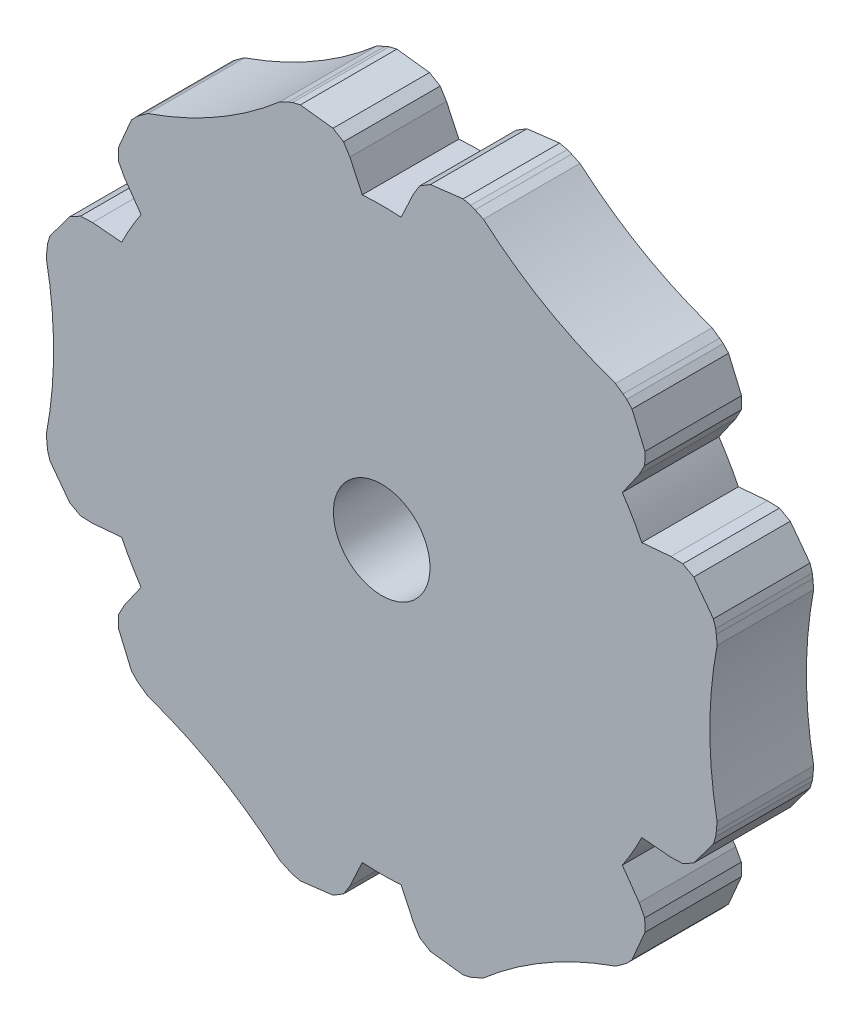
from build123d import *

# Parameters (mm, degrees)
SKETCH1_R           = 3
BOSS_EXTRUDE2_DEPTH = 6
CUT_EXTRUDE1_DEPTH  = 7
CUT_EXTRUDE2_DEPTH  = 7


with BuildPart() as part:
    # Sketch1 → Boss-Extrude2 (new body)
    with BuildSketch(Plane.XY):
        with BuildLine():
            Line((-129.483201213, -12.731798863), (-129.756040866, -10.003402327))
            ThreePointArc((-129.756040866, -10.003402327), (-131.945122685, -10.112584142), (-134.134204503, -10.003402327))
            Line((-134.134204503, -10.003402327), (-134.407044157, -12.731798863))
            ThreePointArc((-134.407044157, -12.731798863), (-142.137187462, -5.76575817), (-152.035027318, -2.554278039))
            Line((-152.035027318, -2.554278039), (-149.808586433, -0.9537937))
            ThreePointArc((-149.808586433, -0.9537937), (-150.997681568, 0.887415858), (-151.997668251, 2.837807232))
            Line((-151.997668251, 2.837807232), (-154.49694879, 1.709895035))
            ThreePointArc((-154.49694879, 1.709895035), (-152.329252239, 11.887415858), (-154.49694879, 22.064936682))
            Line((-154.49694879, 22.064936682), (-151.997668251, 20.937024485))
            ThreePointArc((-151.997668251, 20.937024485), (-150.997681568, 22.887415858), (-149.808586433, 24.728625416))
            Line((-149.808586433, 24.728625416), (-152.035027318, 26.329109756))
            ThreePointArc((-152.035027318, 26.329109756), (-142.137187462, 29.540589886), (-134.407044157, 36.506630579))
            Line((-134.407044157, 36.506630579), (-134.134204503, 33.778234043))
            ThreePointArc((-134.134204503, 33.778234043), (-131.945122685, 33.887415858), (-129.756040866, 33.778234043))
            Line((-129.756040866, 33.778234043), (-129.483201213, 36.506630579))
            ThreePointArc((-129.483201213, 36.506630579), (-121.753057907, 29.540589886), (-111.855218051, 26.329109756))
            Line((-111.855218051, 26.329109756), (-114.081658936, 24.728625416))
            ThreePointArc((-114.081658936, 24.728625416), (-112.892563801, 22.887415858), (-111.892577118, 20.937024485))
            Line((-111.892577118, 20.937024485), (-109.393296579, 22.064936682))
            ThreePointArc((-109.393296579, 22.064936682), (-111.56099313, 11.887415858), (-109.393296579, 1.709895035))
            Line((-109.393296579, 1.709895035), (-111.892577118, 2.837807232))
            ThreePointArc((-111.892577118, 2.837807232), (-112.892563801, 0.887415858), (-114.081658936, -0.9537937))
            Line((-114.081658936, -0.9537937), (-111.855218051, -2.554278039))
            ThreePointArc((-111.855218051, -2.554278039), (-121.753057907, -5.76575817), (-129.483201213, -12.731798863))
        make_face()
        with Locations((-131.945122685, 11.887415858)):
            Circle(SKETCH1_R, mode=Mode.SUBTRACT)
    extrude(amount=BOSS_EXTRUDE2_DEPTH)

    # Sketch2 → Cut-Extrude1 (cut, through all)
    with BuildSketch(Plane(origin=(0, 0, 0), x_dir=(-1, 0, 0), z_dir=(0, 0, -1))):
        with BuildLine():
            ThreePointArc((130.738332945, 29.846952186), (131.945122685, 29.887451596), (133.151912424, 29.846952186))
            Line((133.151912424, 29.846952186), (134.365507242, 32.447465558))
            Line((134.365507242, 32.447465558), (137.658457935, 32.842028481))
            ThreePointArc((137.658457935, 32.842028481), (135.942681801, 34.594415702), (134.407044157, 36.506630579))
            Line((134.407044157, 36.506630579), (134.134204503, 33.778234043))
            ThreePointArc((134.134204503, 33.778234043), (131.945122685, 33.887415858), (129.756040866, 33.778234043))
            Line((129.756040866, 33.778234043), (129.483201213, 36.506630579))
            ThreePointArc((129.483201213, 36.506630579), (127.947563568, 34.594415702), (126.231787434, 32.842028481))
            Line((126.231787434, 32.842028481), (129.524738127, 32.447465558))
            Line((129.524738127, 32.447465558), (130.738332945, 29.846952186))
        make_face()
        with BuildLine():
            Line((148.540455749, 24.263555222), (146.895142515, 21.912294593))
            ThreePointArc((146.895142515, 21.912294593), (147.533610903, 20.887433727), (148.101932254, 19.82207345))
            Line((148.101932254, 19.82207345), (150.960840307, 20.071326194))
            Line((150.960840307, 20.071326194), (152.949017168, 17.416828703))
            ThreePointArc((152.949017168, 17.416828703), (153.608740951, 19.778928032), (154.49694879, 22.064936682))
            Line((154.49694879, 22.064936682), (151.997668251, 20.937024485))
            ThreePointArc((151.997668251, 20.937024485), (150.997681568, 22.887415858), (149.808586433, 24.728625416))
            Line((149.808586433, 24.728625416), (152.035027318, 26.329109756))
            ThreePointArc((152.035027318, 26.329109756), (149.611181835, 26.702903528), (147.235681918, 27.312615637))
            Line((147.235681918, 27.312615637), (148.540455749, 24.263555222))
        make_face()
        with BuildLine():
            ThreePointArc((115.788313115, 19.82207345), (116.356634466, 20.887433727), (116.995102855, 21.912294593))
            Line((116.995102855, 21.912294593), (115.34978962, 24.263555222))
            Line((115.34978962, 24.263555222), (116.654563452, 27.312615637))
            ThreePointArc((116.654563452, 27.312615637), (114.279063535, 26.702903528), (111.855218051, 26.329109756))
            Line((111.855218051, 26.329109756), (114.081658936, 24.728625416))
            ThreePointArc((114.081658936, 24.728625416), (112.892563801, 22.887415858), (111.892577118, 20.937024485))
            Line((111.892577118, 20.937024485), (109.393296579, 22.064936682))
            ThreePointArc((109.393296579, 22.064936682), (110.281504418, 19.778928032), (110.941228201, 17.416828703))
            Line((110.941228201, 17.416828703), (112.929405062, 20.071326194))
            Line((112.929405062, 20.071326194), (115.788313115, 19.82207345))
        make_face()
        with BuildLine():
            Line((150.960840307, 3.703505522), (148.101932254, 3.952758266))
            ThreePointArc((148.101932254, 3.952758266), (147.533610903, 2.887397989), (146.895142515, 1.862537123))
            Line((146.895142515, 1.862537123), (148.540455749, -0.488723506))
            Line((148.540455749, -0.488723506), (147.235681918, -3.537783921))
            ThreePointArc((147.235681918, -3.537783921), (149.611181835, -2.928071812), (152.035027318, -2.554278039))
            Line((152.035027318, -2.554278039), (149.808586433, -0.9537937))
            ThreePointArc((149.808586433, -0.9537937), (150.997681568, 0.887415858), (151.997668251, 2.837807232))
            Line((151.997668251, 2.837807232), (154.49694879, 1.709895035))
            ThreePointArc((154.49694879, 1.709895035), (153.608740951, 3.995903684), (152.949017168, 6.358003014))
            Line((152.949017168, 6.358003014), (150.960840307, 3.703505522))
        make_face()
        with BuildLine():
            ThreePointArc((116.995102855, 1.862537123), (116.356634466, 2.887397989), (115.788313115, 3.952758266))
            Line((115.788313115, 3.952758266), (112.929405062, 3.703505522))
            Line((112.929405062, 3.703505522), (110.941228201, 6.358003014))
            ThreePointArc((110.941228201, 6.358003014), (110.281504418, 3.995903684), (109.393296579, 1.709895035))
            Line((109.393296579, 1.709895035), (111.892577118, 2.837807232))
            ThreePointArc((111.892577118, 2.837807232), (112.892563801, 0.887415858), (114.081658936, -0.9537937))
            Line((114.081658936, -0.9537937), (111.855218051, -2.554278039))
            ThreePointArc((111.855218051, -2.554278039), (114.279063535, -2.928071812), (116.654563452, -3.537783921))
            Line((116.654563452, -3.537783921), (115.34978962, -0.488723506))
            Line((115.34978962, -0.488723506), (116.995102855, 1.862537123))
        make_face()
        with BuildLine():
            Line((134.365507242, -8.672633842), (133.151912424, -6.072120469))
            ThreePointArc((133.151912424, -6.072120469), (131.945122685, -6.11261988), (130.738332945, -6.072120469))
            Line((130.738332945, -6.072120469), (129.524738127, -8.672633842))
            Line((129.524738127, -8.672633842), (126.231787434, -9.067196765))
            ThreePointArc((126.231787434, -9.067196765), (127.947563568, -10.819583986), (129.483201213, -12.731798863))
            Line((129.483201213, -12.731798863), (129.756040866, -10.003402327))
            ThreePointArc((129.756040866, -10.003402327), (131.945122685, -10.112584142), (134.134204503, -10.003402327))
            Line((134.134204503, -10.003402327), (134.407044157, -12.731798863))
            ThreePointArc((134.407044157, -12.731798863), (135.942681801, -10.819583986), (137.658457935, -9.067196765))
            Line((137.658457935, -9.067196765), (134.365507242, -8.672633842))
        make_face()
    extrude(amount=-CUT_EXTRUDE1_DEPTH, mode=Mode.SUBTRACT)

    # Sketch5 → Cut-Extrude2 (cut, through all)
    with BuildSketch(Plane(origin=(0, 0, 0), x_dir=(-1, 0, 0), z_dir=(0, 0, -1))):
        Polygon((130.20552592, 31.11947551), (129.574953313, 32.121497093), (129.310917186, 32.281735325), (128.697286189, 32.654135676), (127.366259017, 32.873895382), (126.416214667, 32.654135676), (126.147436582, 32.54260411), (125.218815368, 32.111317334), (126.147436582, 39.612839074), (129.890239616, 35.341275211), align=None)
        Polygon((137.742808787, 39.612839074), (134.000005753, 35.341275211), (133.68471945, 31.11947551), (134.315292057, 32.121497093), (134.579328183, 32.281735325), (135.19295918, 32.654135676), (136.523986352, 32.873895382), (137.474030702, 32.654135676), (137.742808787, 32.54260411), (138.671430002, 32.111317334), align=None)
        Polygon((151.553547848, 19.458066854), (152.409378922, 18.415243363), (152.694083609, 17.482600968), (152.731883481, 17.194066536), (152.822688785, 16.174213586), (158.854886572, 20.729184019), (153.284202235, 21.834764595), (149.470373293, 19.996910693), (150.653435743, 19.951829588), (150.924224185, 19.803286711), align=None)
        Polygon((148.290018687, 24.365864472), (148.305711352, 25.083484679), (147.830515254, 26.346067876), (147.165175591, 27.058950565), (146.934197379, 27.235953431), (146.096381468, 27.824519606), (153.05720047, 30.771070914), (151.229319167, 25.393926474), (147.730776528, 23.009980675), (148.283266371, 24.057083363), align=None)
        Polygon((148.305711352, -1.308652963), (147.830515254, -2.57123616), (147.165175591, -3.284118849), (146.934197379, -3.461121715), (146.096381468, -4.04968789), (153.05720047, -6.996239198), (151.229319167, -1.619094757), (147.730776528, 0.764851041), (148.283266371, -0.282251647), (148.290018687, -0.591032756), align=None)
        Polygon((150.924224185, 3.971545005), (151.553547848, 4.316764862), (152.409378922, 5.359588353), (152.694083609, 6.292230748), (152.731883481, 6.58076518), (152.822688785, 7.60061813), (158.854886572, 3.045647698), (153.284202235, 1.940067121), (149.470373293, 3.777921023), (150.653435743, 3.823002128), align=None)
        Polygon((128.697286189, -8.87930396), (127.366259017, -9.099063665), (126.416214667, -8.87930396), (126.147436582, -8.767772393), (125.218815368, -8.336485618), (126.147436582, -15.838007358), (129.890239616, -11.566443495), (130.20552592, -7.344643794), (129.574953313, -8.346665377), (129.310917186, -8.506903609), align=None)
        Polygon((134.579328183, -8.506903609), (135.19295918, -8.87930396), (136.523986352, -9.099063665), (137.474030702, -8.87930396), (137.742808787, -8.767772393), (138.671430002, -8.336485618), (137.742808787, -15.838007358), (134.000005753, -11.566443495), (133.68471945, -7.344643794), (134.315292057, -8.346665377), align=None)
        Polygon((112.336697522, 4.316764862), (111.480866448, 5.359588353), (111.19616176, 6.292230748), (111.158361888, 6.58076518), (111.067556584, 7.60061813), (105.035358798, 3.045647698), (110.606043134, 1.940067121), (114.419872076, 3.777921023), (113.236809627, 3.823002128), (112.966021184, 3.971545005), align=None)
        Polygon((115.600226683, -0.591032756), (115.584534017, -1.308652963), (116.059730115, -2.57123616), (116.725069778, -3.284118849), (116.95604799, -3.461121715), (117.793863901, -4.04968789), (110.8330449, -6.996239198), (112.660926203, -1.619094757), (116.159468841, 0.764851041), (115.606978999, -0.282251647), align=None)
        Polygon((115.584534017, 25.083484679), (116.059730115, 26.346067876), (116.725069778, 27.058950565), (116.95604799, 27.235953431), (117.793863901, 27.824519606), (110.8330449, 30.771070914), (112.660926203, 25.393926474), (116.159468841, 23.009980675), (115.606978999, 24.057083363), (115.600226683, 24.365864472), align=None)
        Polygon((112.966021184, 19.803286711), (112.336697522, 19.458066854), (111.480866448, 18.415243363), (111.19616176, 17.482600968), (111.158361888, 17.194066536), (111.067556584, 16.174213586), (105.035358798, 20.729184019), (110.606043134, 21.834764595), (114.419872076, 19.996910693), (113.236809627, 19.951829588), align=None)
    extrude(amount=-CUT_EXTRUDE2_DEPTH, mode=Mode.SUBTRACT)


solid = part.part
